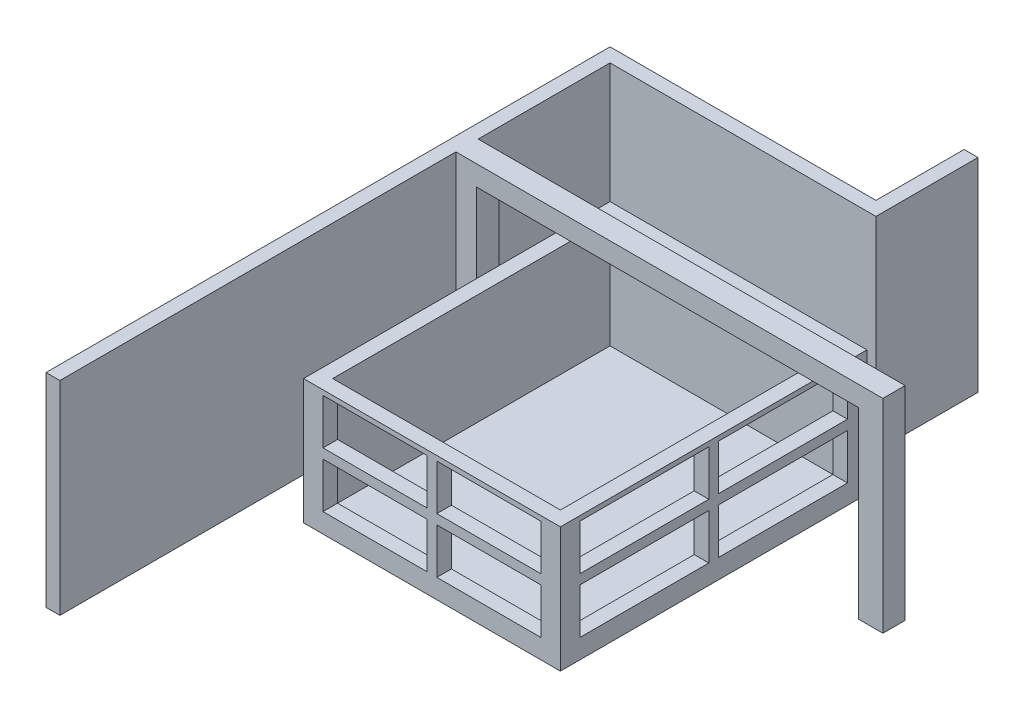
from build123d import *

# Parameters (mm, degrees)
SKETCH1_W             = 3700
SKETCH1_H             = 4415
SKETCH1_W_2           = 3280
SKETCH1_H_2           = 3995
BOSS_EXTRUDE1_DEPTH   = 210
SKETCH1_3_W           = 3700
SKETCH1_3_H           = 4415
SKETCH1_3_W_2         = 3280
SKETCH1_3_H_2         = 3995
BOSS_EXTRUDE2_DEPTH   = 1800
CUT_EXTRUDE1_REACH    = 5116.169
SKETCH2_W             = 1500
SKETCH2_H             = 655
CUT_EXTRUDE2_START    = -4415
SKETCH2_3_W           = 1500
SKETCH2_3_H           = 655
CUT_EXTRUDE2_DEPTH    = 200
CUT_EXTRUDE3_REACH    = 4671.374
SKETCH3_W             = 1857.5
SKETCH3_H             = 655
CUT_EXTRUDE4_START    = -3700
SKETCH3_3_W           = 1857.5
SKETCH3_3_H           = 655
CUT_EXTRUDE4_DEPTH    = 200
SKETCH4_W             = 350
SKETCH4_H             = 320
BOSS_EXTRUDE3_DEPTH   = 2640
SKETCH4_W_2           = 300
BOSS_EXTRUDE3_2_DEPTH = 2640
SKETCH5_W             = 6150
SKETCH5_H             = 320
BOSS_EXTRUDE4_DEPTH   = 290
BOSS_EXTRUDE5_DEPTH   = 2930


with BuildPart() as part:
    # Sketch1 → Boss-Extrude1 (new body)
    with BuildSketch(Plane(origin=(0, 0, 0), x_dir=(1, 0, 0), z_dir=(0, 1, 0))):
        Rectangle(SKETCH1_W, SKETCH1_H)
        Rectangle(SKETCH1_W_2, SKETCH1_H_2, mode=Mode.SUBTRACT)
        Rectangle(SKETCH1_W_2, SKETCH1_H_2)
    extrude(amount=BOSS_EXTRUDE1_DEPTH)

    # Sketch1_3 → Boss-Extrude2 (add)
    with BuildSketch(Plane(origin=(0, 0, 0), x_dir=(1, 0, 0), z_dir=(0, 1, 0))):
        Rectangle(SKETCH1_3_W, SKETCH1_3_H)
        Rectangle(SKETCH1_3_W_2, SKETCH1_3_H_2, mode=Mode.SUBTRACT)
    extrude(amount=BOSS_EXTRUDE2_DEPTH)

    # Sketch2 → Cut-Extrude1 (cut, up to next)
    with BuildSketch(Plane.XY.offset(2207.5), mode=Mode.PRIVATE) as cut_extrude1_sk1:
        with Locations((-820, 1402.5)):
            Rectangle(SKETCH2_W, SKETCH2_H)
    cut_extrude1_tool1 = extrude(cut_extrude1_sk1.sketch, amount=-CUT_EXTRUDE1_REACH, mode=Mode.PRIVATE) & part.part
    # Sketch2 → Cut-Extrude1 (cut, up to next)
    with BuildSketch(Plane.XY.offset(2207.5), mode=Mode.PRIVATE) as cut_extrude1_sk2:
        with Locations((-820, 607.5)):
            Rectangle(SKETCH2_W, SKETCH2_H)
    cut_extrude1_tool2 = extrude(cut_extrude1_sk2.sketch, amount=-CUT_EXTRUDE1_REACH, mode=Mode.PRIVATE) & part.part
    # Sketch2 → Cut-Extrude1 (cut, up to next)
    with BuildSketch(Plane.XY.offset(2207.5), mode=Mode.PRIVATE) as cut_extrude1_sk3:
        with Locations((820, 607.5)):
            Rectangle(SKETCH2_W, SKETCH2_H)
    cut_extrude1_tool3 = extrude(cut_extrude1_sk3.sketch, amount=-CUT_EXTRUDE1_REACH, mode=Mode.PRIVATE) & part.part
    # Sketch2 → Cut-Extrude1 (cut, up to next)
    with BuildSketch(Plane.XY.offset(2207.5), mode=Mode.PRIVATE) as cut_extrude1_sk4:
        with Locations((820, 1402.5)):
            Rectangle(SKETCH2_W, SKETCH2_H)
    cut_extrude1_tool4 = extrude(cut_extrude1_sk4.sketch, amount=-CUT_EXTRUDE1_REACH, mode=Mode.PRIVATE) & part.part
    add(cut_extrude1_tool1.solids().sort_by_distance((-820, 1402.5, 2207.5))[0], mode=Mode.SUBTRACT)
    add(cut_extrude1_tool2.solids().sort_by_distance((-820, 607.5, 2207.5))[0], mode=Mode.SUBTRACT)
    add(cut_extrude1_tool3.solids().sort_by_distance((820, 607.5, 2207.5))[0], mode=Mode.SUBTRACT)
    add(cut_extrude1_tool4.solids().sort_by_distance((820, 1402.5, 2207.5))[0], mode=Mode.SUBTRACT)

    # Sketch2_3 → Cut-Extrude2 (cut)
    with BuildSketch(Plane.XY.offset(2207.5).offset(CUT_EXTRUDE2_START)):
        with Locations((820, 1402.5)):
            Rectangle(SKETCH2_3_W, SKETCH2_3_H)
        with Locations((-820, 1402.5)):
            Rectangle(SKETCH2_3_W, SKETCH2_3_H)
        with Locations((-820, 607.5)):
            Rectangle(SKETCH2_3_W, SKETCH2_3_H)
        with Locations((820, 607.5)):
            Rectangle(SKETCH2_3_W, SKETCH2_3_H)
    extrude(amount=CUT_EXTRUDE2_DEPTH, mode=Mode.SUBTRACT)

    # Sketch3 → Cut-Extrude3 (cut, up to next)
    with BuildSketch(Plane(origin=(1850, 0, 0), x_dir=(0, 0, -1), z_dir=(1, 0, 0)), mode=Mode.PRIVATE) as cut_extrude3_sk1:
        with Locations((-998.75, 1402.5)):
            Rectangle(SKETCH3_W, SKETCH3_H)
    cut_extrude3_tool1 = extrude(cut_extrude3_sk1.sketch, amount=-CUT_EXTRUDE3_REACH, mode=Mode.PRIVATE) & part.part
    # Sketch3 → Cut-Extrude3 (cut, up to next)
    with BuildSketch(Plane(origin=(1850, 0, 0), x_dir=(0, 0, -1), z_dir=(1, 0, 0)), mode=Mode.PRIVATE) as cut_extrude3_sk2:
        with Locations((-998.75, 607.5)):
            Rectangle(SKETCH3_W, SKETCH3_H)
    cut_extrude3_tool2 = extrude(cut_extrude3_sk2.sketch, amount=-CUT_EXTRUDE3_REACH, mode=Mode.PRIVATE) & part.part
    # Sketch3 → Cut-Extrude3 (cut, up to next)
    with BuildSketch(Plane(origin=(1850, 0, 0), x_dir=(0, 0, -1), z_dir=(1, 0, 0)), mode=Mode.PRIVATE) as cut_extrude3_sk3:
        with Locations((998.75, 607.5)):
            Rectangle(SKETCH3_W, SKETCH3_H)
    cut_extrude3_tool3 = extrude(cut_extrude3_sk3.sketch, amount=-CUT_EXTRUDE3_REACH, mode=Mode.PRIVATE) & part.part
    # Sketch3 → Cut-Extrude3 (cut, up to next)
    with BuildSketch(Plane(origin=(1850, 0, 0), x_dir=(0, 0, -1), z_dir=(1, 0, 0)), mode=Mode.PRIVATE) as cut_extrude3_sk4:
        with Locations((998.75, 1402.5)):
            Rectangle(SKETCH3_W, SKETCH3_H)
    cut_extrude3_tool4 = extrude(cut_extrude3_sk4.sketch, amount=-CUT_EXTRUDE3_REACH, mode=Mode.PRIVATE) & part.part
    add(cut_extrude3_tool1.solids().sort_by_distance((1850, 1402.5, 998.75))[0], mode=Mode.SUBTRACT)
    add(cut_extrude3_tool2.solids().sort_by_distance((1850, 607.5, 998.75))[0], mode=Mode.SUBTRACT)
    add(cut_extrude3_tool3.solids().sort_by_distance((1850, 607.5, -998.75))[0], mode=Mode.SUBTRACT)
    add(cut_extrude3_tool4.solids().sort_by_distance((1850, 1402.5, -998.75))[0], mode=Mode.SUBTRACT)

    # Sketch3_3 → Cut-Extrude4 (cut)
    with BuildSketch(Plane(origin=(1850, 0, 0), x_dir=(0, 0, -1), z_dir=(1, 0, 0)).offset(CUT_EXTRUDE4_START)):
        with Locations((998.75, 607.5)):
            Rectangle(SKETCH3_3_W, SKETCH3_3_H)
        with Locations((998.75, 1402.5)):
            Rectangle(SKETCH3_3_W, SKETCH3_3_H)
        with Locations((-998.75, 1402.5)):
            Rectangle(SKETCH3_3_W, SKETCH3_3_H)
        with Locations((-998.75, 607.5)):
            Rectangle(SKETCH3_3_W, SKETCH3_3_H)
    extrude(amount=CUT_EXTRUDE4_DEPTH, mode=Mode.SUBTRACT)


with BuildPart() as body_2:
    # Sketch4 → Boss-Extrude3 (new body)
    with BuildSketch(Plane(origin=(0, 0, 0), x_dir=(1, 0, 0), z_dir=(0, 1, 0))):
        with Locations((3525, 747.5)):
            Rectangle(SKETCH4_W, SKETCH4_H)
    extrude(amount=BOSS_EXTRUDE3_DEPTH)



with BuildPart() as body_3:
    # Sketch4 → Boss-Extrude3 2 (new body)
    with BuildSketch(Plane(origin=(0, 0, 0), x_dir=(1, 0, 0), z_dir=(0, 1, 0))):
        with Locations((-2300, 747.5)):
            Rectangle(SKETCH4_W_2, SKETCH4_H)
    extrude(amount=BOSS_EXTRUDE3_2_DEPTH)


with BuildPart() as body_2_1:
    add(body_2.part)

    add(body_3.part)  # Boss-Extrude4 merges body 3
    # Sketch5 → Boss-Extrude4 (add)
    with BuildSketch(Plane(origin=(0, 2640, 0), x_dir=(1, 0, 0), z_dir=(0, 1, 0))):
        with Locations((625, 747.5)):
            Rectangle(SKETCH5_W, SKETCH5_H)
    extrude(amount=BOSS_EXTRUDE4_DEPTH)

    # Sketch4_3 → Boss-Extrude5 (add)
    with BuildSketch(Plane(origin=(0, 0, 0), x_dir=(1, 0, 0), z_dir=(0, 1, 0))):
        Polygon((1180, 4277.475628021), (1180, 3007.5), (-2650, 3007.5), (-2650, -5116.768477228), (-2450, -5116.768477228), (-2450, 587.5), (-2450, 907.5), (-2450, 2807.5), (1380, 2807.5), (1380, 4277.475628021), align=None)
    extrude(amount=BOSS_EXTRUDE5_DEPTH)


solid = Compound([part.part, body_2_1.part])
